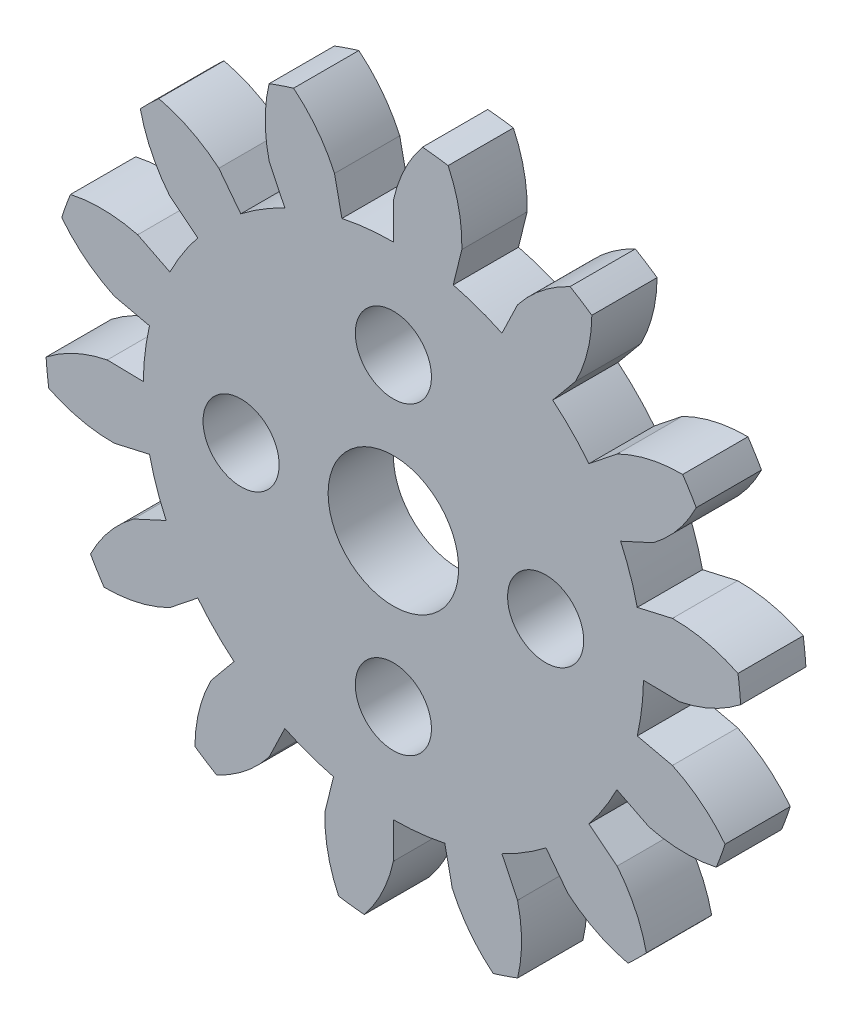
from build123d import *

# Parameters (mm, degrees)
BOSS_EXTRU_1_DEPTH           = 3
R_P_TITION_CIRCULAIRE2_COUNT = 14
ESQUISSE5_R                  = 11.5
BOSS_EXTRU_2_DEPTH           = 3
ESQUISSE6_R                  = 3
ESQUISSE6_R_2                = 1.75
ENL_V_MAT_EXTRU_1_DEPTH      = 4


with BuildPart() as part:
    # Esquisse4 → Boss.-Extru.1 (new body)
    with BuildSketch(Plane.XY):
        with BuildLine():
            Line((0, 13.155696691), (0, 11.5))
            ThreePointArc((0, 11.5), (1.385979557, 11.416175396), (2.751754038, 11.165923594))
            Line((2.751754038, 11.165923594), (3.147934042, 12.773522094))
            ThreePointArc((3.147934042, 12.773522094), (3.010357566, 14.324173734), (2.517223611, 15.800746352))
            ThreePointArc((2.517223611, 15.800746352), (1.928319383, 15.883374464), (1.336751397, 15.944061456))
            ThreePointArc((1.336751397, 15.944061456), (0.504624377, 14.628382005), (0, 13.155696691))
        make_face()
    extrude(amount=BOSS_EXTRU_1_DEPTH)


with BuildPart() as r_p_tition_circulaire2_1:
    # Répétition circulaire2: pattern copy
    add(part.part.rotate(Axis((0, 0, 0), (0, 0, 1)), 1 * 360 / R_P_TITION_CIRCULAIRE2_COUNT))


with BuildPart() as r_p_tition_circulaire2_2:
    # Répétition circulaire2: pattern copy
    add(part.part.rotate(Axis((0, 0, 0), (0, 0, 1)), 2 * 360 / R_P_TITION_CIRCULAIRE2_COUNT))


with BuildPart() as r_p_tition_circulaire2_3:
    # Répétition circulaire2: pattern copy
    add(part.part.rotate(Axis((0, 0, 0), (0, 0, 1)), 3 * 360 / R_P_TITION_CIRCULAIRE2_COUNT))


with BuildPart() as r_p_tition_circulaire2_4:
    # Répétition circulaire2: pattern copy
    add(part.part.rotate(Axis((0, 0, 0), (0, 0, 1)), 4 * 360 / R_P_TITION_CIRCULAIRE2_COUNT))


with BuildPart() as r_p_tition_circulaire2_5:
    # Répétition circulaire2: pattern copy
    add(part.part.rotate(Axis((0, 0, 0), (0, 0, 1)), 5 * 360 / R_P_TITION_CIRCULAIRE2_COUNT))


with BuildPart() as r_p_tition_circulaire2_6:
    # Répétition circulaire2: pattern copy
    add(part.part.rotate(Axis((0, 0, 0), (0, 0, 1)), 6 * 360 / R_P_TITION_CIRCULAIRE2_COUNT))


with BuildPart() as r_p_tition_circulaire2_7:
    # Répétition circulaire2: pattern copy
    add(part.part.rotate(Axis((0, 0, 0), (0, 0, 1)), 7 * 360 / R_P_TITION_CIRCULAIRE2_COUNT))


with BuildPart() as r_p_tition_circulaire2_8:
    # Répétition circulaire2: pattern copy
    add(part.part.rotate(Axis((0, 0, 0), (0, 0, 1)), 8 * 360 / R_P_TITION_CIRCULAIRE2_COUNT))


with BuildPart() as r_p_tition_circulaire2_9:
    # Répétition circulaire2: pattern copy
    add(part.part.rotate(Axis((0, 0, 0), (0, 0, 1)), 9 * 360 / R_P_TITION_CIRCULAIRE2_COUNT))


with BuildPart() as r_p_tition_circulaire2_10:
    # Répétition circulaire2: pattern copy
    add(part.part.rotate(Axis((0, 0, 0), (0, 0, 1)), 10 * 360 / R_P_TITION_CIRCULAIRE2_COUNT))


with BuildPart() as r_p_tition_circulaire2_11:
    # Répétition circulaire2: pattern copy
    add(part.part.rotate(Axis((0, 0, 0), (0, 0, 1)), 11 * 360 / R_P_TITION_CIRCULAIRE2_COUNT))


with BuildPart() as r_p_tition_circulaire2_12:
    # Répétition circulaire2: pattern copy
    add(part.part.rotate(Axis((0, 0, 0), (0, 0, 1)), 12 * 360 / R_P_TITION_CIRCULAIRE2_COUNT))


with BuildPart() as r_p_tition_circulaire2_13:
    # Répétition circulaire2: pattern copy
    add(part.part.rotate(Axis((0, 0, 0), (0, 0, 1)), 13 * 360 / R_P_TITION_CIRCULAIRE2_COUNT))


with BuildPart() as part_1:
    add(part.part)

    add(r_p_tition_circulaire2_1.part)  # Boss.-Extru.2 merges Répétition circulaire2_1

    add(r_p_tition_circulaire2_2.part)  # Boss.-Extru.2 merges Répétition circulaire2_2

    add(r_p_tition_circulaire2_3.part)  # Boss.-Extru.2 merges Répétition circulaire2_3

    add(r_p_tition_circulaire2_4.part)  # Boss.-Extru.2 merges Répétition circulaire2_4

    add(r_p_tition_circulaire2_5.part)  # Boss.-Extru.2 merges Répétition circulaire2_5

    add(r_p_tition_circulaire2_6.part)  # Boss.-Extru.2 merges Répétition circulaire2_6

    add(r_p_tition_circulaire2_7.part)  # Boss.-Extru.2 merges Répétition circulaire2_7

    add(r_p_tition_circulaire2_8.part)  # Boss.-Extru.2 merges Répétition circulaire2_8

    add(r_p_tition_circulaire2_9.part)  # Boss.-Extru.2 merges Répétition circulaire2_9

    add(r_p_tition_circulaire2_10.part)  # Boss.-Extru.2 merges Répétition circulaire2_10

    add(r_p_tition_circulaire2_11.part)  # Boss.-Extru.2 merges Répétition circulaire2_11

    add(r_p_tition_circulaire2_12.part)  # Boss.-Extru.2 merges Répétition circulaire2_12

    add(r_p_tition_circulaire2_13.part)  # Boss.-Extru.2 merges Répétition circulaire2_13
    # Esquisse5 → Boss.-Extru.2 (add)
    with BuildSketch(Plane.XY):
        Circle(ESQUISSE5_R)
    extrude(amount=BOSS_EXTRU_2_DEPTH)

    # Esquisse6 → Enlèv. mat.-Extru.1 (cut, through all)
    with BuildSketch(Plane(origin=(0, 0, 0), x_dir=(-1, 0, 0), z_dir=(0, 0, -1))):
        Circle(ESQUISSE6_R)
        with Locations((0, 7)):
            Circle(ESQUISSE6_R_2)
        with Locations((7, 0)):
            Circle(ESQUISSE6_R_2)
        with Locations((0, -7)):
            Circle(ESQUISSE6_R_2)
        with Locations((-7, 0)):
            Circle(ESQUISSE6_R_2)
    extrude(amount=-ENL_V_MAT_EXTRU_1_DEPTH, mode=Mode.SUBTRACT)


solid = part_1.part
